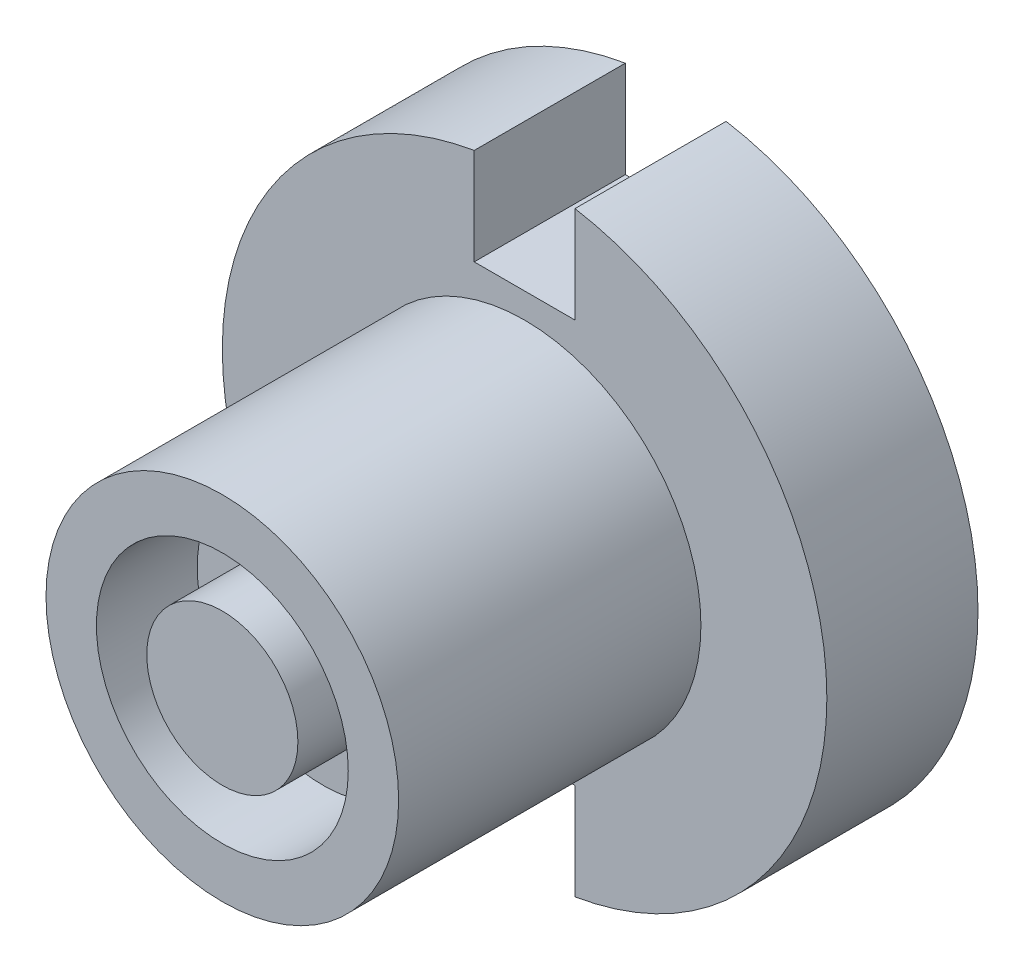
from build123d import *

# Parameters (mm, degrees)
CROQUIS1_R              = 3.5
SALIENTE_EXTRUIR1_DEPTH = 6
CROQUIS2_R              = 6
SALIENTE_EXTRUIR2_DEPTH = 3
CROQUIS3_R              = 2.5
CROQUIS3_R_2            = 1.5
CORTAR_EXTRUIR1_DEPTH   = 2
CROQUIS4_W              = 2
CROQUIS4_H              = 2
CORTAR_EXTRUIR2_DEPTH   = 4


with BuildPart() as part:
    # Croquis1 → Saliente-Extruir1 (new body)
    with BuildSketch(Plane.XY):
        with Locations((-4.754102012, 3.97833761)):
            Circle(CROQUIS1_R)
    extrude(amount=SALIENTE_EXTRUIR1_DEPTH)

    # Croquis2 → Saliente-Extruir2 (add)
    with BuildSketch(Plane(origin=(0, 0, 0), x_dir=(-1, 0, 0), z_dir=(0, 0, -1))):
        with Locations((4.754102012, 3.97833761)):
            Circle(CROQUIS2_R)
    extrude(amount=SALIENTE_EXTRUIR2_DEPTH)

    # Croquis3 → Cortar-Extruir1 (cut)
    with BuildSketch(Plane.XY.offset(6)):
        with Locations((-4.754102012, 3.97833761)):
            Circle(CROQUIS3_R)
        with Locations((-4.754102012, 3.97833761)):
            Circle(CROQUIS3_R_2, mode=Mode.SUBTRACT)
    extrude(amount=-CORTAR_EXTRUIR1_DEPTH, mode=Mode.SUBTRACT)

    # Croquis4 → Cortar-Extruir2 (cut, through all)
    with BuildSketch(Plane.XY):
        with Locations((-4.754102012, 8.97833761)):
            Rectangle(CROQUIS4_W, CROQUIS4_H)
        Polygon((-5.754102012, -0.02166239), (-3.754102012, -0.02166239), (-3.754102012, -2.02166239), (-4.754102012, -2.02166239), (-5.754102012, -2.02166239), align=None)
    extrude(amount=-CORTAR_EXTRUIR2_DEPTH, mode=Mode.SUBTRACT)


solid = part.part
